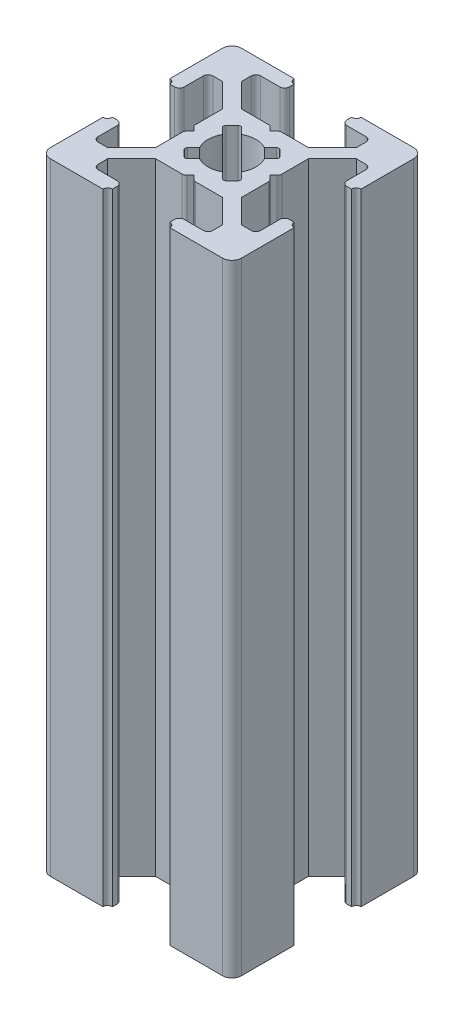
from build123d import *

# Parameters (mm, degrees)
BOSS_EXTRUDE1_DEPTH = 65
FILLET1_R           = 1
CUT_EXTRUDE1_DEPTH  = 66
FILLET2_R           = 0.5
FILLET3_R           = 0.25


with BuildPart() as part:
    # Sketch3 → Boss-Extrude1 (new body)
    with BuildSketch(Plane(origin=(0, 0, 0), x_dir=(1, 0, 0), z_dir=(0, 1, 0))):
        with BuildLine():
            Line((7, 18.5), (7, 19.5))
            ThreePointArc((7, 19.5), (6.646446609, 19.646446609), (6.5, 20))
            Line((6.5, 20), (0, 20))
            Line((0, 20), (0, 13.5))
            ThreePointArc((0, 13.5), (0.353553391, 13.353553391), (0.5, 13))
            Line((0.5, 13), (1.5, 13))
            Line((1.5, 13), (1.5, 16))
            Line((1.5, 16), (3, 16))
            Line((3, 16), (5.5, 13.5))
            Line((5.5, 13.5), (5.5, 10.5))
            Line((5.5, 10.5), (6, 10))
            Line((6, 10), (5.5, 9.5))
            Line((5.5, 9.5), (5.5, 6.5))
            Line((5.5, 6.5), (3, 4))
            Line((3, 4), (1.5, 4))
            Line((1.5, 4), (1.5, 7))
            Line((1.5, 7), (0.5, 7))
            ThreePointArc((0.5, 7), (0.353553391, 6.646446609), (0, 6.5))
            Line((0, 6.5), (0, 0))
            Line((0, 0), (6.5, 0))
            ThreePointArc((6.5, 0), (6.646446609, 0.353553391), (7, 0.5))
            Line((7, 0.5), (7, 1.5))
            Line((7, 1.5), (4, 1.5))
            Line((4, 1.5), (4, 3))
            Line((4, 3), (6.5, 5.5))
            Line((6.5, 5.5), (9.5, 5.5))
            Line((9.5, 5.5), (10, 6))
            Line((10, 6), (10.5, 5.5))
            Line((10.5, 5.5), (13.5, 5.5))
            Line((13.5, 5.5), (16, 3))
            Line((16, 3), (16, 1.5))
            Line((16, 1.5), (13, 1.5))
            Line((13, 1.5), (13, 0.5))
            ThreePointArc((13, 0.5), (13.353553391, 0.353553391), (13.5, 0))
            Line((13.5, 0), (20, 0))
            Line((20, 0), (20, 6.5))
            ThreePointArc((20, 6.5), (19.646446609, 6.646446609), (19.5, 7))
            Line((19.5, 7), (18.5, 7))
            Line((18.5, 7), (18.5, 4))
            Line((18.5, 4), (17, 4))
            Line((17, 4), (14.5, 6.5))
            Line((14.5, 6.5), (14.5, 9.5))
            Line((14.5, 9.5), (14, 10))
            Line((14, 10), (14.5, 10.5))
            Line((14.5, 10.5), (14.5, 13.5))
            Line((14.5, 13.5), (17, 16))
            Line((17, 16), (18.5, 16))
            Line((18.5, 16), (18.5, 13))
            Line((18.5, 13), (19.5, 13))
            ThreePointArc((19.5, 13), (19.646446609, 13.353553391), (20, 13.5))
            Line((20, 13.5), (20, 20))
            Line((20, 20), (13.5, 20))
            ThreePointArc((13.5, 20), (13.353553391, 19.646446609), (13, 19.5))
            Line((13, 19.5), (13, 18.5))
            Line((13, 18.5), (16, 18.5))
            Line((16, 18.5), (16, 17))
            Line((16, 17), (13.5, 14.5))
            Line((13.5, 14.5), (10.5, 14.5))
            Line((10.5, 14.5), (10, 14))
            Line((10, 14), (9.5, 14.5))
            Line((9.5, 14.5), (6.5, 14.5))
            Line((6.5, 14.5), (4, 17))
            Line((4, 17), (4, 18.5))
            Line((4, 18.5), (7, 18.5))
        make_face()
    extrude(amount=BOSS_EXTRUDE1_DEPTH)

    # Fillet1
    fillet1_edges = [part.edges().sort_by_distance(p)[0] for p in [
        (20, 32.5, 0),
        (0, 32.5, 0),
        (0, 32.5, -20),
        (20, 32.5, -20),
    ]]
    fillet(fillet1_edges, radius=FILLET1_R)

    # Sketch4 → Cut-Extrude1 (cut, through all)
    with BuildSketch(Plane(origin=(0, 65, 0), x_dir=(1, 0, 0), z_dir=(0, 1, 0))):
        with BuildLine():
            Line((10, 11), (11.195582496, 12.195582496))
            ThreePointArc((11.195582496, 12.195582496), (10, 12.5), (8.804417504, 12.195582496))
            Line((8.804417504, 12.195582496), (10, 11))
        make_face()
        with BuildLine():
            ThreePointArc((12.195582496, 11.195582496), (11.767766953, 11.767766953), (11.195582496, 12.195582496))
            Line((11.195582496, 12.195582496), (10, 11))
            Line((10, 11), (11, 10))
            Line((11, 10), (12.195582496, 11.195582496))
        make_face()
        with BuildLine():
            Line((9, 10), (10, 11))
            Line((10, 11), (8.804417504, 12.195582496))
            ThreePointArc((8.804417504, 12.195582496), (8.232233047, 11.767766953), (7.804417504, 11.195582496))
            Line((7.804417504, 11.195582496), (9, 10))
        make_face()
        Polygon((11, 10), (10, 11), (9, 10), (10, 9), align=None)
        with BuildLine():
            Line((7.804417504, 8.804417504), (9, 10))
            Line((9, 10), (7.804417504, 11.195582496))
            ThreePointArc((7.804417504, 11.195582496), (7.5, 10), (7.804417504, 8.804417504))
        make_face()
        with BuildLine():
            Line((10, 9), (9, 10))
            Line((9, 10), (7.804417504, 8.804417504))
            ThreePointArc((7.804417504, 8.804417504), (8.232233047, 8.232233047), (8.804417504, 7.804417504))
            Line((8.804417504, 7.804417504), (10, 9))
        make_face()
        with BuildLine():
            Line((11.195582496, 7.804417504), (10, 9))
            Line((10, 9), (8.804417504, 7.804417504))
            ThreePointArc((8.804417504, 7.804417504), (10, 7.5), (11.195582496, 7.804417504))
        make_face()
        with BuildLine():
            Line((12.195582496, 8.804417504), (11, 10))
            Line((11, 10), (10, 9))
            Line((10, 9), (11.195582496, 7.804417504))
            ThreePointArc((11.195582496, 7.804417504), (11.767766953, 8.232233047), (12.195582496, 8.804417504))
        make_face()
        with BuildLine():
            ThreePointArc((12.5, 10), (12.422700584, 10.616864556), (12.195582496, 11.195582496))
            Line((12.195582496, 11.195582496), (11, 10))
            Line((11, 10), (12.195582496, 8.804417504))
            ThreePointArc((12.195582496, 8.804417504), (12.422700584, 9.383135444), (12.5, 10))
        make_face()
        with BuildLine():
            ThreePointArc((8.804417504, 7.804417504), (8.232233047, 8.232233047), (7.804417504, 8.804417504))
            Line((7.804417504, 8.804417504), (7, 8))
            Line((7, 8), (8, 7))
            Line((8, 7), (8.804417504, 7.804417504))
        make_face()
        with BuildLine():
            Line((13, 8), (12.195582496, 8.804417504))
            ThreePointArc((12.195582496, 8.804417504), (11.767766953, 8.232233047), (11.195582496, 7.804417504))
            Line((11.195582496, 7.804417504), (12, 7))
            Line((12, 7), (13, 8))
        make_face()
        with BuildLine():
            Line((13, 12), (12, 13))
            Line((12, 13), (11.195582496, 12.195582496))
            ThreePointArc((11.195582496, 12.195582496), (11.767766953, 11.767766953), (12.195582496, 11.195582496))
            Line((12.195582496, 11.195582496), (13, 12))
        make_face()
        with BuildLine():
            ThreePointArc((7.804417504, 11.195582496), (8.232233047, 11.767766953), (8.804417504, 12.195582496))
            Line((8.804417504, 12.195582496), (8, 13))
            Line((8, 13), (7, 12))
            Line((7, 12), (7.804417504, 11.195582496))
        make_face()
    extrude(amount=-CUT_EXTRUDE1_DEPTH, mode=Mode.SUBTRACT)

    # Fillet2
    fillet2_edges = [part.edges().sort_by_distance(p)[0] for p in [
        (18.5, 32.5, -13),
        (18.5, 32.5, -16),
        (14.5, 32.5, -10.5),
        (14.5, 32.5, -9.5),
        (18.5, 32.5, -4),
        (18.5, 32.5, -7),
        (13, 32.5, -1.5),
        (16, 32.5, -1.5),
        (10.5, 32.5, -5.5),
        (9.5, 32.5, -5.5),
        (4, 32.5, -1.5),
        (7, 32.5, -1.5),
        (1.5, 32.5, -7),
        (1.5, 32.5, -4),
        (5.5, 32.5, -9.5),
        (5.5, 32.5, -10.5),
        (1.5, 32.5, -16),
        (1.5, 32.5, -13),
        (7, 32.5, -18.5),
        (4, 32.5, -18.5),
        (9.5, 32.5, -14.5),
        (10.5, 32.5, -14.5),
        (16, 32.5, -18.5),
        (13, 32.5, -18.5),
    ]]
    fillet(fillet2_edges, radius=FILLET2_R)

    # Fillet3
    fillet3_edges = [part.edges().sort_by_distance(p)[0] for p in [
        (7, 32.5, -12),
        (8, 32.5, -13),
        (12, 32.5, -13),
        (13, 32.5, -12),
        (13, 32.5, -8),
        (12, 32.5, -7),
        (8, 32.5, -7),
        (7, 32.5, -8),
    ]]
    fillet(fillet3_edges, radius=FILLET3_R)


solid = part.part
